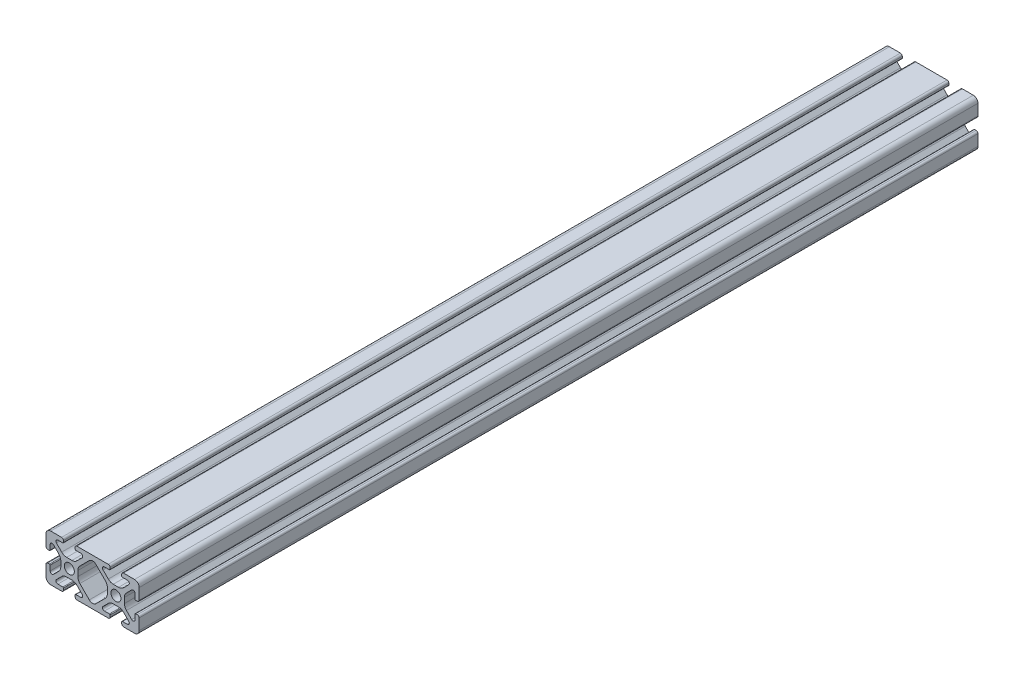
from build123d import *

# Parameters (mm, degrees)
CROQUIS1_R              = 2.15
SALIENTE_EXTRUIR1_DEPTH = 360


with BuildPart() as part:
    # Croquis1 → Saliente-Extruir1 (new body)
    with BuildSketch(Plane.XY.offset(20)):
        with BuildLine():
            Line((32.499999987, 1.499999997), (32.499999987, 0.800000002))
            ThreePointArc((32.499999987, 0.800000002), (32.734314563, 0.234314576), (33.29999999, 0))
            Line((33.29999999, 0), (38, 0))
            ThreePointArc((38, 0), (39.414213562, 0.585786438), (40, 2))
            Line((40, 2), (40, 6.700000003))
            ThreePointArc((40, 6.700000003), (39.765685425, 7.265685427), (39.2, 7.500000003))
            Line((39.2, 7.500000003), (38.499999996, 7.500000003))
            ThreePointArc((38.499999996, 7.500000003), (38.287867962, 7.412132037), (38.199999996, 7.200000003))
            Line((38.199999996, 7.200000003), (38.199999996, 5.082411612))
            ThreePointArc((38.199999996, 5.082411612), (37.686138518, 4.313363563), (36.778984492, 4.493807718))
            Line((36.778984492, 4.493807718), (34.528679652, 6.744112558))
            ThreePointArc((34.528679652, 6.744112558), (33.878361399, 7.717382603), (33.649999997, 8.865432898))
            Line((33.649999997, 8.865432898), (33.649999997, 11.134567109))
            ThreePointArc((33.649999997, 11.134567109), (33.878361399, 12.282617405), (34.528679653, 13.255887451))
            Line((34.528679653, 13.255887451), (36.778984498, 15.506192296))
            ThreePointArc((36.778984498, 15.506192296), (37.68613852, 15.686636451), (38.199999996, 14.917588405))
            Line((38.199999996, 14.917588405), (38.199999996, 12.800000003))
            ThreePointArc((38.199999996, 12.800000003), (38.287867963, 12.587867967), (38.499999999, 12.5))
            Line((38.499999999, 12.5), (39.199999998, 12.5))
            ThreePointArc((39.199999998, 12.5), (39.765685424, 12.734314576), (40, 13.300000002))
            Line((40, 13.300000002), (40, 18))
            ThreePointArc((40, 18), (39.414213562, 19.414213562), (38, 20))
            Line((38, 20), (33.299999987, 20))
            ThreePointArc((33.299999987, 20), (32.734314562, 19.765685425), (32.499999987, 19.2))
            Line((32.499999987, 19.2), (32.499999987, 18.499999997))
            ThreePointArc((32.499999987, 18.499999997), (32.587867953, 18.287867963), (32.799999987, 18.199999997))
            Line((32.799999987, 18.199999997), (34.917587986, 18.199999997))
            ThreePointArc((34.917587986, 18.199999997), (35.686635927, 17.686138592), (35.506191797, 16.778984693))
            Line((35.506191797, 16.778984693), (33.255886766, 14.528679662))
            ThreePointArc((33.255886766, 14.528679662), (32.282616721, 13.878361409), (31.134566426, 13.650000007))
            Line((31.134566426, 13.650000007), (28.86543289, 13.650000007))
            ThreePointArc((28.86543289, 13.650000007), (27.717382593, 13.878361409), (26.744112547, 14.528679663))
            Line((26.744112547, 14.528679663), (24.493807707, 16.778984503))
            ThreePointArc((24.493807707, 16.778984503), (24.313363553, 17.686138523), (25.082411597, 18.199999997))
            Line((25.082411597, 18.199999997), (27.199999997, 18.199999997))
            ThreePointArc((27.199999997, 18.199999997), (27.412132033, 18.287867964), (27.5, 18.5))
            Line((27.5, 18.5), (27.5, 19.199999998))
            ThreePointArc((27.5, 19.199999998), (27.265685424, 19.765685424), (26.699999997, 20))
            Line((26.699999997, 20), (13.299999987, 20))
            ThreePointArc((13.299999987, 20), (12.734314562, 19.765685425), (12.499999987, 19.2))
            Line((12.499999987, 19.2), (12.499999987, 18.499999997))
            ThreePointArc((12.499999987, 18.499999997), (12.587867953, 18.287867963), (12.799999987, 18.199999997))
            Line((12.799999987, 18.199999997), (14.917588389, 18.199999997))
            ThreePointArc((14.917588389, 18.199999997), (15.686636438, 17.686138519), (15.506192283, 16.778984493))
            Line((15.506192283, 16.778984493), (13.255887452, 14.528679662))
            ThreePointArc((13.255887452, 14.528679662), (12.282617407, 13.878361409), (11.134567112, 13.650000007))
            Line((11.134567112, 13.650000007), (8.86543289, 13.650000007))
            ThreePointArc((8.86543289, 13.650000007), (7.717382593, 13.878361409), (6.744112547, 14.528679663))
            Line((6.744112547, 14.528679663), (4.493807707, 16.778984503))
            ThreePointArc((4.493807707, 16.778984503), (4.313363553, 17.686138523), (5.082411597, 18.199999997))
            Line((5.082411597, 18.199999997), (7.199999997, 18.199999997))
            ThreePointArc((7.199999997, 18.199999997), (7.412132033, 18.287867964), (7.5, 18.5))
            Line((7.5, 18.5), (7.5, 19.199999998))
            ThreePointArc((7.5, 19.199999998), (7.265685424, 19.765685424), (6.699999997, 20))
            Line((6.699999997, 20), (2, 20))
            ThreePointArc((2, 20), (0.585786438, 19.414213562), (0, 18))
            Line((0, 18), (0, 13.3))
            ThreePointArc((0, 13.3), (0.234314575, 12.734314575), (0.8, 12.5))
            Line((0.8, 12.5), (1.500000005, 12.5))
            ThreePointArc((1.500000005, 12.5), (1.71213204, 12.587867966), (1.800000005, 12.8))
            Line((1.800000005, 12.8), (1.800000005, 14.91758839))
            ThreePointArc((1.800000005, 14.91758839), (2.313861483, 15.686636439), (3.22101551, 15.506192284))
            Line((3.22101551, 15.506192284), (5.471320341, 13.255887453))
            ThreePointArc((5.471320341, 13.255887453), (6.121638594, 12.282617408), (6.349999996, 11.134567113))
            Line((6.349999996, 11.134567113), (6.349999996, 8.865432892))
            ThreePointArc((6.349999996, 8.865432892), (6.121638593, 7.717382596), (5.47132034, 6.74411255))
            Line((5.47132034, 6.74411255), (3.2210155, 4.49380771))
            ThreePointArc((3.2210155, 4.49380771), (2.31386148, 4.313363556), (1.800000005, 5.0824116))
            Line((1.800000005, 5.0824116), (1.800000005, 7.2))
            ThreePointArc((1.800000005, 7.2), (1.712132039, 7.412132036), (1.500000003, 7.500000003))
            Line((1.500000003, 7.500000003), (0.800000003, 7.500000003))
            ThreePointArc((0.800000003, 7.500000003), (0.234314576, 7.265685427), (0, 6.7))
            Line((0, 6.7), (0, 2))
            ThreePointArc((0, 2), (0.585786438, 0.585786438), (2, 0))
            Line((2, 0), (6.7, 0))
            ThreePointArc((6.7, 0), (7.265685425, 0.234314575), (7.5, 0.8))
            Line((7.5, 0.8), (7.5, 1.5))
            ThreePointArc((7.5, 1.5), (7.412132034, 1.712132034), (7.2, 1.8))
            Line((7.2, 1.8), (5.0824116, 1.8))
            ThreePointArc((5.0824116, 1.8), (4.313363551, 2.313861478), (4.493807706, 3.221015504))
            Line((4.493807706, 3.221015504), (6.744112546, 5.471320344))
            ThreePointArc((6.744112546, 5.471320344), (7.717382591, 6.121638597), (8.865432886, 6.349999999))
            Line((8.865432886, 6.349999999), (11.134567108, 6.349999999))
            ThreePointArc((11.134567108, 6.349999999), (12.282617404, 6.121638597), (13.25588745, 5.471320343))
            Line((13.25588745, 5.471320343), (15.506192295, 3.221015498))
            ThreePointArc((15.506192295, 3.221015498), (15.686636449, 2.313861476), (14.917588403, 1.8))
            Line((14.917588403, 1.8), (12.79999999, 1.8))
            ThreePointArc((12.79999999, 1.8), (12.587867954, 1.712132033), (12.499999987, 1.499999997))
            Line((12.499999987, 1.499999997), (12.499999987, 0.800000003))
            ThreePointArc((12.499999987, 0.800000003), (12.734314563, 0.234314576), (13.29999999, 0))
            Line((13.29999999, 0), (26.7, 0))
            ThreePointArc((26.7, 0), (27.265685425, 0.234314575), (27.5, 0.8))
            Line((27.5, 0.8), (27.5, 1.5))
            ThreePointArc((27.5, 1.5), (27.412132034, 1.712132034), (27.2, 1.8))
            Line((27.2, 1.8), (25.0824116, 1.8))
            ThreePointArc((25.0824116, 1.8), (24.313363551, 2.313861478), (24.493807706, 3.221015504))
            Line((24.493807706, 3.221015504), (26.744112546, 5.471320344))
            ThreePointArc((26.744112546, 5.471320344), (27.717382591, 6.121638597), (28.865432886, 6.349999999))
            Line((28.865432886, 6.349999999), (31.134567114, 6.349999999))
            ThreePointArc((31.134567114, 6.349999999), (32.282617411, 6.121638597), (33.255887457, 5.471320343))
            Line((33.255887457, 5.471320343), (35.506192392, 3.221015408))
            ThreePointArc((35.506192392, 3.221015408), (35.686636535, 2.313861443), (34.917588538, 1.8))
            Line((34.917588538, 1.8), (32.79999999, 1.8))
            ThreePointArc((32.79999999, 1.8), (32.587867954, 1.712132033), (32.499999987, 1.499999997))
        make_face()
        with Locations((10, 10)):
            Circle(CROQUIS1_R, mode=Mode.SUBTRACT)
        with Locations((30, 10)):
            Circle(CROQUIS1_R, mode=Mode.SUBTRACT)
        with BuildLine():
            Line((18.585786097, 2.687006113), (14.528679097, 6.744113113))
            ThreePointArc((14.528679097, 6.744113113), (13.878360843, 7.717383159), (13.649999441, 8.865433456))
            Line((13.649999441, 8.865433456), (13.649999441, 11.134566554))
            ThreePointArc((13.649999441, 11.134566554), (13.878360843, 12.282616849), (14.528679096, 13.255886895))
            Line((14.528679096, 13.255886895), (18.585786441, 17.312994239))
            ThreePointArc((18.585786441, 17.312994239), (20.000000001, 17.898780676), (21.414213561, 17.312994239))
            Line((21.414213561, 17.312994239), (25.471320216, 13.255887584))
            ThreePointArc((25.471320216, 13.255887584), (26.12163847, 12.282617538), (26.349999872, 11.13456724))
            Line((26.349999872, 11.13456724), (26.349999872, 8.865433454))
            ThreePointArc((26.349999872, 8.865433454), (26.12163847, 7.717383158), (25.471320217, 6.744113113))
            Line((25.471320217, 6.744113113), (21.414213217, 2.687006113))
            ThreePointArc((21.414213217, 2.687006113), (19.999999657, 2.101219676), (18.585786097, 2.687006113))
        make_face(mode=Mode.SUBTRACT)
    extrude(amount=-SALIENTE_EXTRUIR1_DEPTH)


solid = part.part
